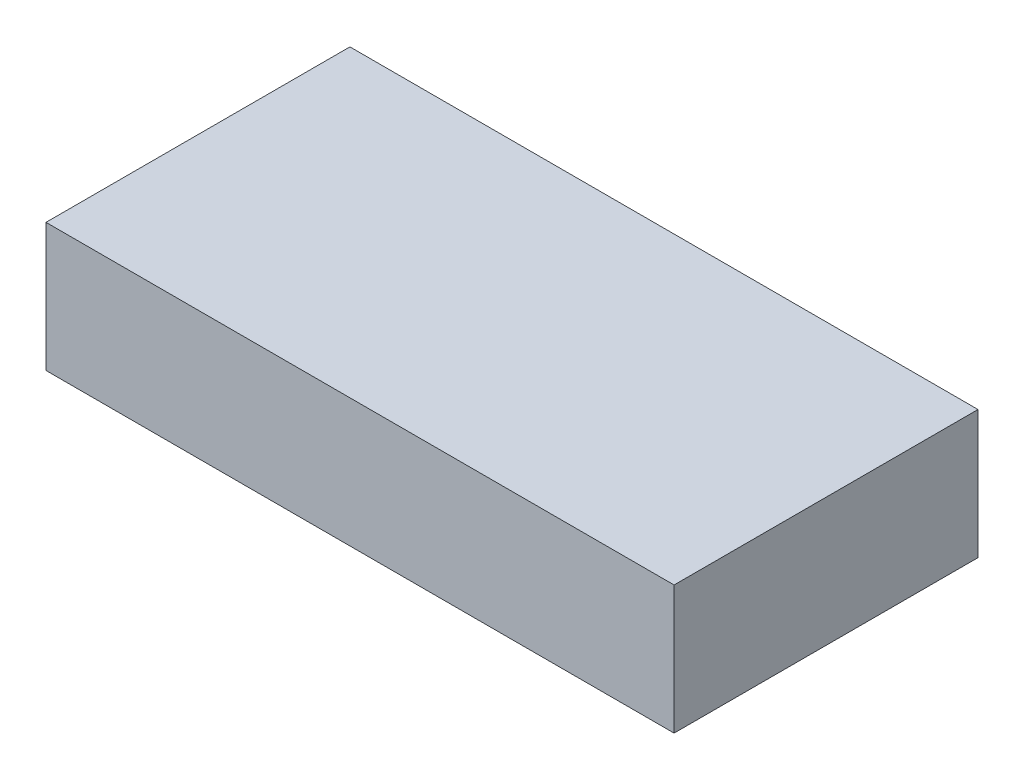
from build123d import *

# Parameters (mm, degrees)
SKETCH1_W           = 70.866
SKETCH1_H           = 34.29
BOSS_EXTRUDE1_DEPTH = 14.478


with BuildPart() as part:
    # Sketch1 → Boss-Extrude1 (new body)
    with BuildSketch(Plane(origin=(0, 0, 0), x_dir=(1, 0, 0), z_dir=(0, 1, 0))):
        with Locations((12.328071429, -4.439330357)):
            Rectangle(SKETCH1_W, SKETCH1_H)
    extrude(amount=BOSS_EXTRUDE1_DEPTH)


solid = part.part
